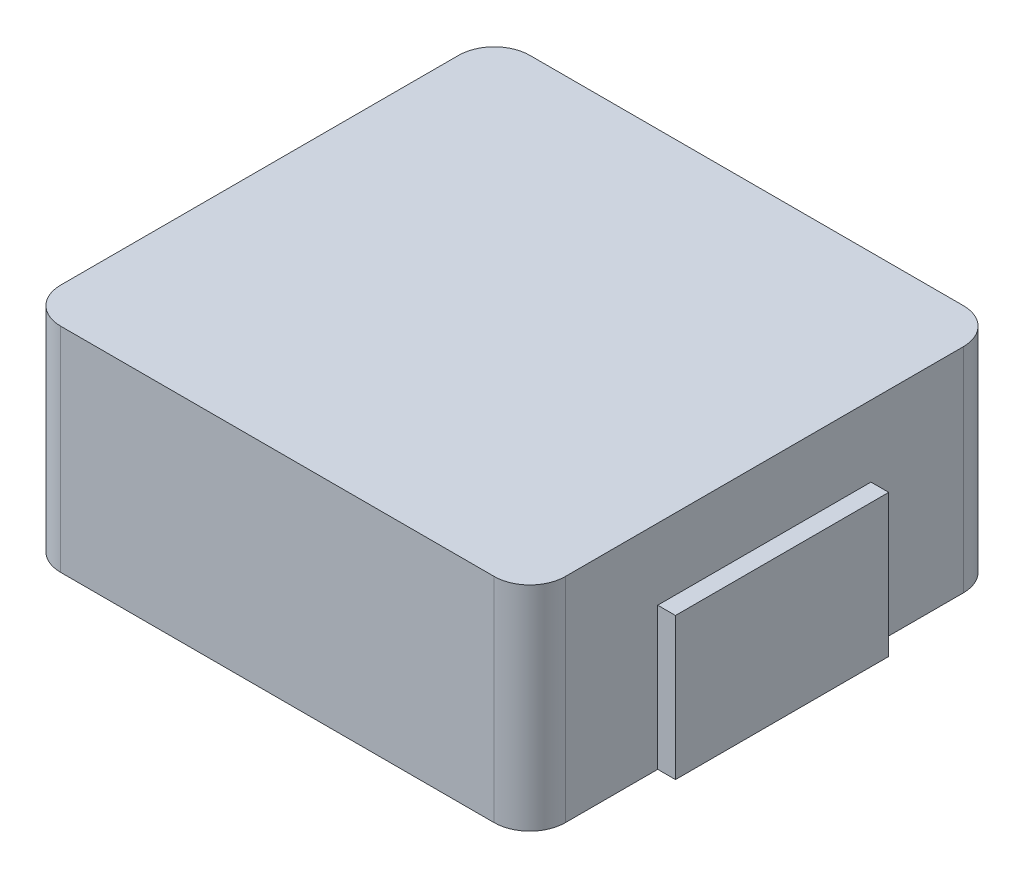
from build123d import *

# Parameters (mm, degrees)
SKETCH_1_W      = 7.1
SKETCH_1_H      = 6.6
EXTRUDE_1_DEPTH = 3
FILLET_1_R      = 0.5
SKETCH_2_W      = 0.5
SKETCH_2_H      = 3
EXTRUDE_2_DEPTH = 2


with BuildPart() as part:
    # 草图1 → 凸台-拉伸1 (new body)
    with BuildSketch(Plane(origin=(0, 0, 0), x_dir=(1, 0, 0), z_dir=(0, 1, 0))):
        Rectangle(SKETCH_1_W, SKETCH_1_H)
    extrude(amount=EXTRUDE_1_DEPTH)

    # 圆角1
    fillet_1_edges = [part.edges().sort_by_distance(p)[0] for p in [
        (3.55, 1.5, 3.3),
        (-3.55, 1.5, 3.3),
        (-3.55, 1.5, -3.3),
        (3.55, 1.5, -3.3),
    ]]
    fillet(fillet_1_edges, radius=FILLET_1_R)

    # 草图2 → 凸台-拉伸2 (add)
    with BuildSketch(Plane.XZ):
        with Locations((-3.55, 0)):
            Rectangle(SKETCH_2_W, SKETCH_2_H)
        with Locations((3.55, 0)):
            Rectangle(SKETCH_2_W, SKETCH_2_H)
    extrude(amount=-EXTRUDE_2_DEPTH)


solid = part.part
